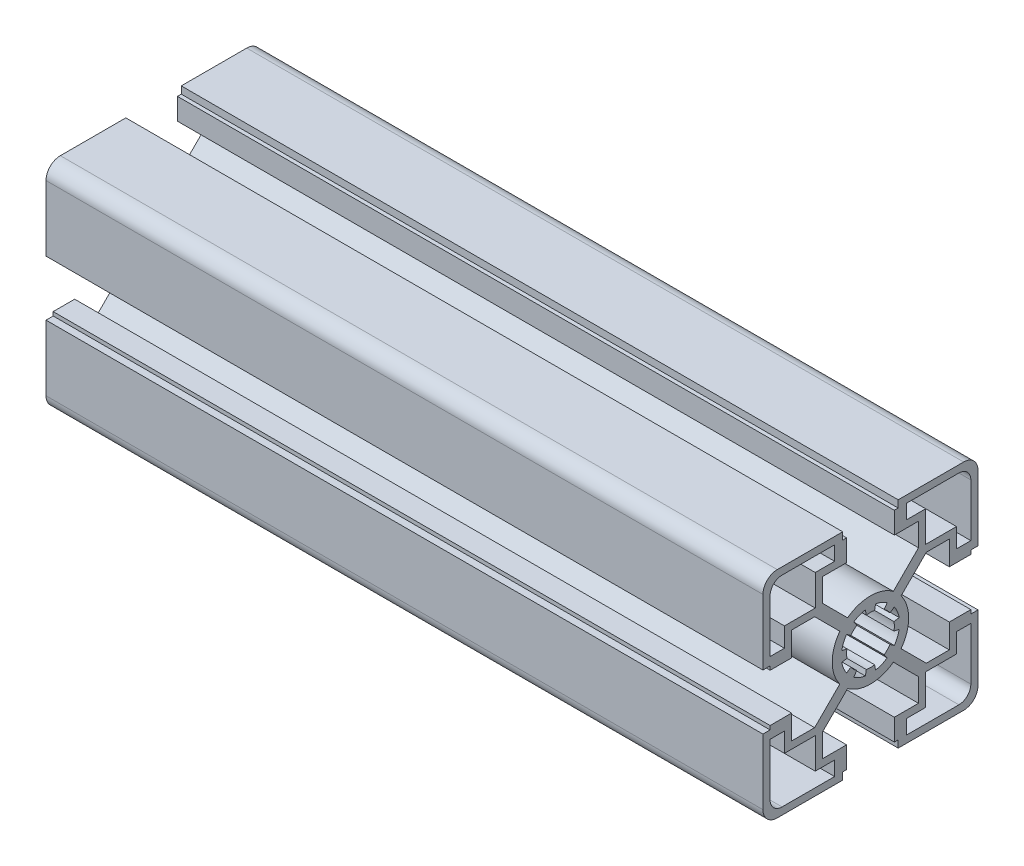
from build123d import *

# Parameters (mm, degrees)
BR_EXTRUDE_DEPTH      = 97.5
BR_EXTRUDE_DEPTH_BACK = 52.5


with BuildPart() as part:
    # Sketch2 → BR_Extrude (new body, two sides)
    with BuildSketch(Plane(origin=(0, 0, 0), x_dir=(0, 0, -1), z_dir=(1, 0, 0))) as br_extrude_sk:
        with BuildLine():
            Line((-10.05, 11.676345597), (-10.05, 16.5))
            Line((-10.05, 16.5), (-5, 16.5))
            Line((-5, 16.5), (-5, 21))
            Line((-5, 21), (-5.8, 21))
            Line((-5.8, 21), (-5.8, 22.5))
            Line((-5.8, 22.5), (-19.5, 22.5))
            ThreePointArc((-19.5, 22.5), (-21.621320344, 21.621320344), (-22.5, 19.5))
            Line((-22.5, 19.5), (-22.5, 5.8))
            Line((-22.5, 5.8), (-21, 5.8))
            Line((-21, 5.8), (-21, 5))
            Line((-21, 5), (-16.5, 5))
            Line((-16.5, 5), (-16.5, 10.05))
            Line((-16.5, 10.05), (-11.676345597, 10.05))
            Line((-11.676345597, 10.05), (-6.411275155, 4.784929559))
            ThreePointArc((-6.411275155, 4.784929559), (-8, 0), (-6.411275155, -4.784929559))
            Line((-6.411275155, -4.784929559), (-11.676345597, -10.05))
            Line((-11.676345597, -10.05), (-16.5, -10.05))
            Line((-16.5, -10.05), (-16.5, -5))
            Line((-16.5, -5), (-21, -5))
            Line((-21, -5), (-21, -5.8))
            Line((-21, -5.8), (-22.5, -5.8))
            Line((-22.5, -5.8), (-22.5, -19.5))
            ThreePointArc((-22.5, -19.5), (-21.621320344, -21.621320344), (-19.5, -22.5))
            Line((-19.5, -22.5), (-5.8, -22.5))
            Line((-5.8, -22.5), (-5.8, -21))
            Line((-5.8, -21), (-5, -21))
            Line((-5, -21), (-5, -16.5))
            Line((-5, -16.5), (-10.05, -16.5))
            Line((-10.05, -16.5), (-10.05, -11.676345597))
            Line((-10.05, -11.676345597), (-4.784929559, -6.411275155))
            ThreePointArc((-4.784929559, -6.411275155), (0, -8), (4.784929559, -6.411275155))
            Line((4.784929559, -6.411275155), (10.05, -11.676345597))
            Line((10.05, -11.676345597), (10.05, -16.5))
            Line((10.05, -16.5), (5, -16.5))
            Line((5, -16.5), (5, -21))
            Line((5, -21), (5.8, -21))
            Line((5.8, -21), (5.8, -22.5))
            Line((5.8, -22.5), (19.5, -22.5))
            ThreePointArc((19.5, -22.5), (21.621320344, -21.621320344), (22.5, -19.5))
            Line((22.5, -19.5), (22.5, -5.8))
            Line((22.5, -5.8), (21, -5.8))
            Line((21, -5.8), (21, -5))
            Line((21, -5), (16.5, -5))
            Line((16.5, -5), (16.5, -10.05))
            Line((16.5, -10.05), (11.676345597, -10.05))
            Line((11.676345597, -10.05), (6.411275155, -4.784929559))
            ThreePointArc((6.411275155, -4.784929559), (8, 0), (6.411275155, 4.784929559))
            Line((6.411275155, 4.784929559), (11.676345597, 10.05))
            Line((11.676345597, 10.05), (16.5, 10.05))
            Line((16.5, 10.05), (16.5, 5))
            Line((16.5, 5), (21, 5))
            Line((21, 5), (21, 5.8))
            Line((21, 5.8), (22.5, 5.8))
            Line((22.5, 5.8), (22.5, 19.5))
            ThreePointArc((22.5, 19.5), (21.621320344, 21.621320344), (19.5, 22.5))
            Line((19.5, 22.5), (5.8, 22.5))
            Line((5.8, 22.5), (5.8, 21))
            Line((5.8, 21), (5, 21))
            Line((5, 21), (5, 16.5))
            Line((5, 16.5), (10.05, 16.5))
            Line((10.05, 16.5), (10.05, 11.676345597))
            Line((10.05, 11.676345597), (4.784929559, 6.411275155))
            ThreePointArc((4.784929559, 6.411275155), (0, 8), (-4.784929559, 6.411275155))
            Line((-4.784929559, 6.411275155), (-10.05, 11.676345597))
        make_face()
        with BuildLine():
            Line((11.55, 11.55), (11.55, 18))
            Line((11.55, 18), (7.5, 18))
            Line((7.5, 18), (7.5, 21))
            Line((7.5, 21), (18.5, 21))
            ThreePointArc((18.5, 21), (20.267766953, 20.267766953), (21, 18.5))
            Line((21, 18.5), (21, 7.5))
            Line((21, 7.5), (18, 7.5))
            Line((18, 7.5), (18, 11.55))
            Line((18, 11.55), (11.55, 11.55))
        make_face(mode=Mode.SUBTRACT)
        with BuildLine():
            Line((11.55, -11.55), (18, -11.55))
            Line((18, -11.55), (18, -7.5))
            Line((18, -7.5), (21, -7.5))
            Line((21, -7.5), (21, -18.5))
            ThreePointArc((21, -18.5), (20.267766953, -20.267766953), (18.5, -21))
            Line((18.5, -21), (7.5, -21))
            Line((7.5, -21), (7.5, -18))
            Line((7.5, -18), (11.55, -18))
            Line((11.55, -18), (11.55, -11.55))
        make_face(mode=Mode.SUBTRACT)
        with BuildLine():
            Line((-11.55, 11.55), (-18, 11.55))
            Line((-18, 11.55), (-18, 7.5))
            Line((-18, 7.5), (-21, 7.5))
            Line((-21, 7.5), (-21, 18.5))
            ThreePointArc((-21, 18.5), (-20.267766953, 20.267766953), (-18.5, 21))
            Line((-18.5, 21), (-7.5, 21))
            Line((-7.5, 21), (-7.5, 18))
            Line((-7.5, 18), (-11.55, 18))
            Line((-11.55, 18), (-11.55, 11.55))
        make_face(mode=Mode.SUBTRACT)
        with BuildLine():
            Line((-11.55, -11.55), (-11.55, -18))
            Line((-11.55, -18), (-7.5, -18))
            Line((-7.5, -18), (-7.5, -21))
            Line((-7.5, -21), (-18.5, -21))
            ThreePointArc((-18.5, -21), (-20.267766953, -20.267766953), (-21, -18.5))
            Line((-21, -18.5), (-21, -7.5))
            Line((-21, -7.5), (-18, -7.5))
            Line((-18, -7.5), (-18, -11.55))
            Line((-18, -11.55), (-11.55, -11.55))
        make_face(mode=Mode.SUBTRACT)
        with BuildLine():
            Line((-6.007327293, -1.059253884), (-4.924038765, -0.868240888))
            ThreePointArc((-4.924038765, -0.868240888), (-5, 0), (-4.924038765, 0.868240888))
            Line((-4.924038765, 0.868240888), (-6.007327293, 1.059253884))
            ThreePointArc((-6.007327293, 1.059253884), (-5.635665148, 2.334368937), (-4.99682747, 3.498816262))
            Line((-4.99682747, 3.498816262), (-4.095760221, 2.867882182))
            ThreePointArc((-4.095760221, 2.867882182), (-3.535533906, 3.535533906), (-2.867882182, 4.095760221))
            Line((-2.867882182, 4.095760221), (-3.498816262, 4.99682747))
            ThreePointArc((-3.498816262, 4.99682747), (-2.334368937, 5.635665148), (-1.059253884, 6.007327293))
            Line((-1.059253884, 6.007327293), (-0.868240888, 4.924038765))
            ThreePointArc((-0.868240888, 4.924038765), (0, 5), (0.868240888, 4.924038765))
            Line((0.868240888, 4.924038765), (1.059253884, 6.007327293))
            ThreePointArc((1.059253884, 6.007327293), (2.334368937, 5.635665148), (3.498816262, 4.99682747))
            Line((3.498816262, 4.99682747), (2.867882182, 4.095760221))
            ThreePointArc((2.867882182, 4.095760221), (3.535533906, 3.535533906), (4.095760221, 2.867882182))
            Line((4.095760221, 2.867882182), (4.99682747, 3.498816262))
            ThreePointArc((4.99682747, 3.498816262), (5.635665148, 2.334368937), (6.007327293, 1.059253884))
            Line((6.007327293, 1.059253884), (4.924038765, 0.868240888))
            ThreePointArc((4.924038765, 0.868240888), (5, 0), (4.924038765, -0.868240888))
            Line((4.924038765, -0.868240888), (6.007327293, -1.059253884))
            ThreePointArc((6.007327293, -1.059253884), (5.635665148, -2.334368937), (4.99682747, -3.498816262))
            Line((4.99682747, -3.498816262), (4.095760221, -2.867882182))
            ThreePointArc((4.095760221, -2.867882182), (3.535533906, -3.535533906), (2.867882182, -4.095760221))
            Line((2.867882182, -4.095760221), (3.498816262, -4.99682747))
            ThreePointArc((3.498816262, -4.99682747), (2.334368937, -5.635665148), (1.059253884, -6.007327293))
            Line((1.059253884, -6.007327293), (0.868240888, -4.924038765))
            ThreePointArc((0.868240888, -4.924038765), (0, -5), (-0.868240888, -4.924038765))
            Line((-0.868240888, -4.924038765), (-1.059253884, -6.007327293))
            ThreePointArc((-1.059253884, -6.007327293), (-2.334368937, -5.635665148), (-3.498816262, -4.99682747))
            Line((-3.498816262, -4.99682747), (-2.867882182, -4.095760221))
            ThreePointArc((-2.867882182, -4.095760221), (-3.535533906, -3.535533906), (-4.095760221, -2.867882182))
            Line((-4.095760221, -2.867882182), (-4.99682747, -3.498816262))
            ThreePointArc((-4.99682747, -3.498816262), (-5.635665148, -2.334368937), (-6.007327293, -1.059253884))
        make_face(mode=Mode.SUBTRACT)
    extrude(amount=BR_EXTRUDE_DEPTH)
    extrude(br_extrude_sk.sketch, amount=-BR_EXTRUDE_DEPTH_BACK)


solid = part.part
